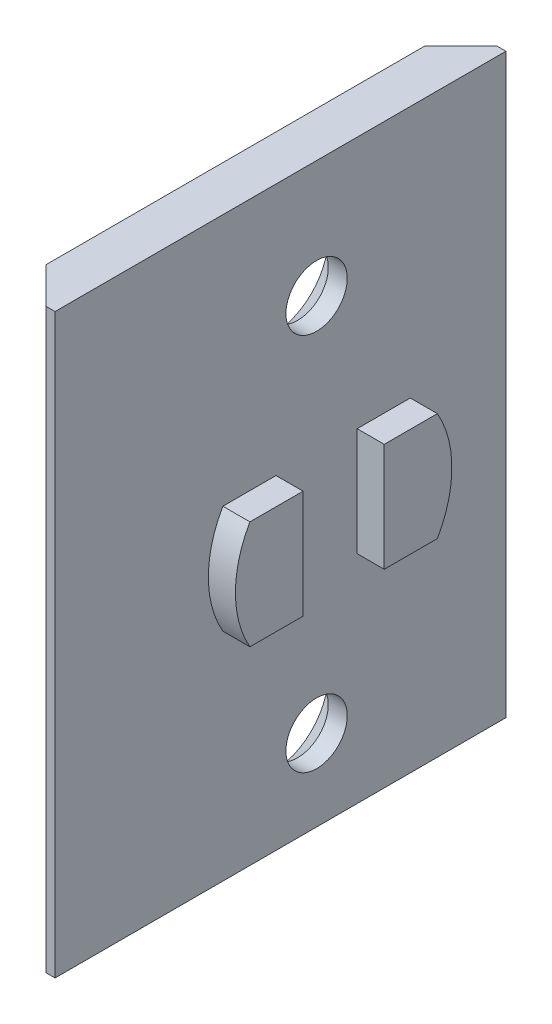
from build123d import *

# Parameters (mm, degrees)
SKETCH_1_W                 = 25
SKETCH_1_H                 = 32
EXTRUDE_1_DEPTH            = 2.5
CHAMFER_1_SIZE             = 2
HOLE_WIZARD_M31_AT_2_COUNT = 2
HOLE_WIZARD_M31_AT_2_PITCH = 21
SKETCH_4_R                 = 6
SKETCH_4_R_2               = 3.5
EXTRUDE_2_DEPTH            = 1.5
SKETCH_5_W                 = 4.5
SKETCH_5_H                 = 16
CUT_EXTRUDE_1_DEPTH        = 1.5
CUT_EXTRUDE_2_DEPTH        = 1.5


with BuildPart() as part:
    # Эскиз1 → Бобышка-Вытянуть1 (new body)
    with BuildSketch(Plane(origin=(0, 0, 0), x_dir=(0, 0, -1), z_dir=(1, 0, 0))):
        Rectangle(SKETCH_1_W, SKETCH_1_H)
    extrude(amount=EXTRUDE_1_DEPTH)

    # Фаска1
    chamfer_1_edges = [part.edges().sort_by_distance(p)[0] for p in [
        (0, 0, 12.5),
        (0, 0, -12.5),
    ]]
    chamfer(chamfer_1_edges, length=CHAMFER_1_SIZE)

    # Эскиз3 → Зенковка для  винта с плоской головкой M31 (revolve, cut)
    with BuildSketch(Plane(origin=(0, -11.5, -2), x_dir=(0, 0, 1), z_dir=(0, 1, 0))):
        Polygon((0, 0), (0, 2.5), (1.7, 2.5), (1.7, 1.45), (3.15, 0), align=None)
    hole_wizard_m31 = revolve(axis=Axis((-6.35, -11.5, -2), (1, 0, 0)), mode=Mode.SUBTRACT)

    # Зенковка для  винта с плоской головкой M31 at 2: Зенковка для  винта с плоской головкой M31 ×2
    with Locations(*[(0, i * HOLE_WIZARD_M31_AT_2_PITCH, 0) for i in range(1, HOLE_WIZARD_M31_AT_2_COUNT)]):
        add(hole_wizard_m31, mode=Mode.SUBTRACT)

    # Эскиз4 → Бобышка-Вытянуть2 (add)
    with BuildSketch(Plane(origin=(2.5, 0, 0), x_dir=(0, 0, -1), z_dir=(1, 0, 0))):
        with Locations((2, -1)):
            Circle(SKETCH_4_R)
        with Locations((2, -1)):
            Circle(SKETCH_4_R_2, mode=Mode.SUBTRACT)
        with BuildLine():
            ThreePointArc((-0.25, 1.680951324), (-1.5, -1), (-0.25, -3.680951324))
            Line((-0.25, -3.680951324), (-0.25, 1.680951324))
        make_face()
        with BuildLine():
            Line((4.25, 1.680951324), (4.25, -3.680951324))
            ThreePointArc((4.25, -3.680951324), (5.172144385, -2.479019946), (5.5, -1))
            ThreePointArc((5.5, -1), (5.172144385, 0.479019946), (4.25, 1.680951324))
        make_face()
    extrude(amount=EXTRUDE_2_DEPTH)

    # Эскиз5 → Вырез-Вытянуть1 (cut)
    with BuildSketch(Plane(origin=(4, 0, 0), x_dir=(0, 0, -1), z_dir=(1, 0, 0))):
        with Locations((2, -1)):
            Rectangle(SKETCH_5_W, SKETCH_5_H)
    extrude(amount=-CUT_EXTRUDE_1_DEPTH, mode=Mode.SUBTRACT)

    # Эскиз6 → Вырез-Вытянуть2 (cut)
    with BuildSketch(Plane(origin=(4, 0, 0), x_dir=(0, 0, -1), z_dir=(1, 0, 0))):
        with BuildLine():
            ThreePointArc((4.25, 4.562148865), (0.047794779, 4.67352578), (-3.196152423, 2))
            Line((-3.196152423, 2), (4.25, 2))
            Line((4.25, 2), (4.25, 4.562148865))
        make_face()
        with BuildLine():
            Line((4.25, 4.562148865), (4.25, 2))
            Line((4.25, 2), (7.196152423, 2))
            ThreePointArc((7.196152423, 2), (5.937314844, 3.527422205), (4.25, 4.562148865))
        make_face()
        with BuildLine():
            Line((4.25, -4), (-3.196152423, -4))
            ThreePointArc((-3.196152423, -4), (0.047794779, -6.67352578), (4.25, -6.562148865))
            Line((4.25, -6.562148865), (4.25, -4))
        make_face()
        with BuildLine():
            Line((7.196152423, -4), (4.25, -4))
            Line((4.25, -4), (4.25, -6.562148865))
            ThreePointArc((4.25, -6.562148865), (5.937314844, -5.527422205), (7.196152423, -4))
        make_face()
    extrude(amount=-CUT_EXTRUDE_2_DEPTH, mode=Mode.SUBTRACT)


solid = part.part
